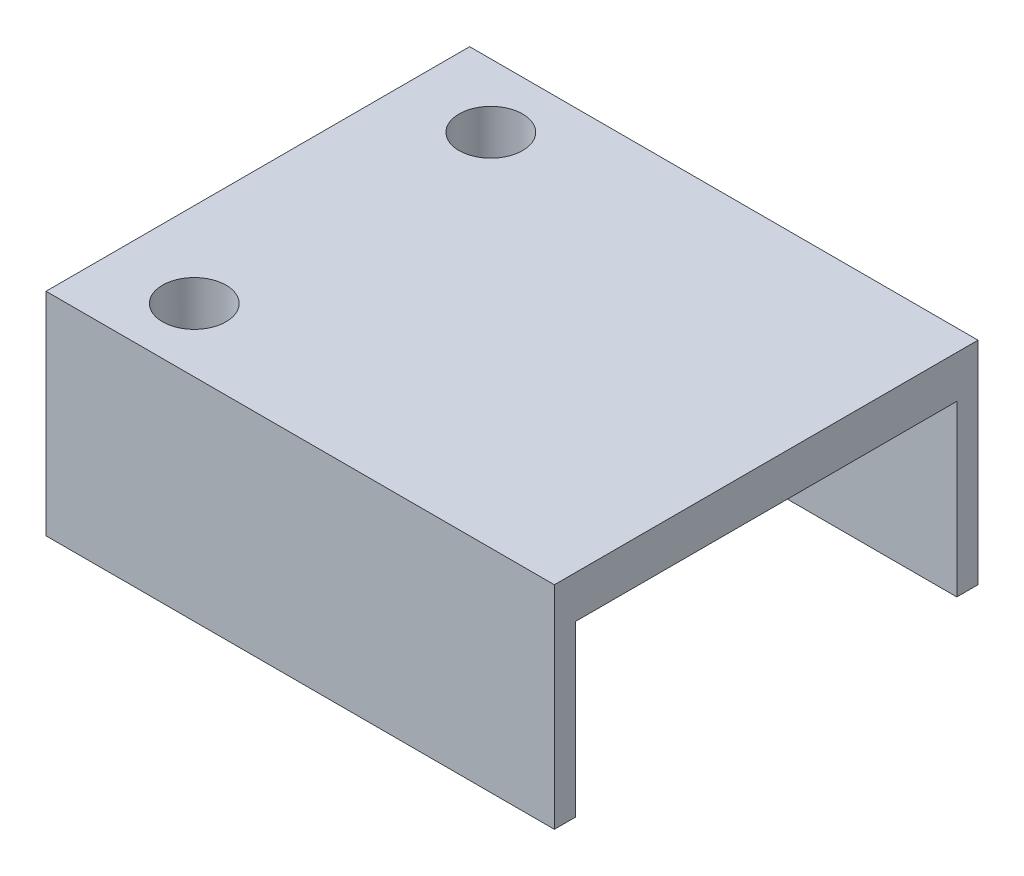
from build123d import *

# Parameters (mm, degrees)
ESQUISSE1_W             = 22
ESQUISSE1_H             = 10
BOSS_EXTRU_1_DEPTH      = 20
ESQUISSE2_R             = 1.5
ENL_V_MAT_EXTRU_1_DEPTH = 20
ESQUISSE4_W             = 18
ESQUISSE4_H             = 8
ENL_V_MAT_EXTRU_6_DEPTH = 18
ESQUISSE5_W             = 20
ESQUISSE5_H             = 10
BOSS_EXTRU_2_DEPTH      = 2
ESQUISSE6_W             = 8.5
ESQUISSE6_H             = 7.090406213
ENL_V_MAT_EXTRU_7_DEPTH = 8
CONG_1_R                = 5


with BuildPart() as part:
    # Esquisse1 → Boss.-Extru.1 (new body)
    with BuildSketch(Plane.XY):
        with Locations((11, 5)):
            Rectangle(ESQUISSE1_W, ESQUISSE1_H)
    extrude(amount=BOSS_EXTRU_1_DEPTH)

    # Esquisse2 → Enlèv. mat.-Extru.1 (cut)
    with BuildSketch(Plane(origin=(0, 10, 0), x_dir=(1, 0, 0), z_dir=(0, 1, 0))):
        with Locations((2, -3)):
            Circle(ESQUISSE2_R)
        with Locations((2, -17)):
            Circle(ESQUISSE2_R)
    extrude(amount=-ENL_V_MAT_EXTRU_1_DEPTH, mode=Mode.SUBTRACT)

    # Esquisse4 → Enlèv. mat.-Extru.6 (cut)
    with BuildSketch(Plane(origin=(22, 0, 0), x_dir=(0, 0, -1), z_dir=(1, 0, 0))):
        with Locations((-10, 4)):
            Rectangle(ESQUISSE4_W, ESQUISSE4_H)
    extrude(amount=-ENL_V_MAT_EXTRU_6_DEPTH, mode=Mode.SUBTRACT)

    # Esquisse5 → Boss.-Extru.2 (add)
    with BuildSketch(Plane.ZY):
        with Locations((10, 5)):
            Rectangle(ESQUISSE5_W, ESQUISSE5_H)
    extrude(amount=BOSS_EXTRU_2_DEPTH)

    # Esquisse6 → Enlèv. mat.-Extru.7 (cut)
    with BuildSketch(Plane.ZY.offset(2)):
        with Locations((10, 3.545203107)):
            Rectangle(ESQUISSE6_W, ESQUISSE6_H)
    extrude(amount=-ENL_V_MAT_EXTRU_7_DEPTH, mode=Mode.SUBTRACT)

    # Congé1
    cong_1_edges = [part.edges().sort_by_distance(p)[0] for p in [
        (4, 4, 1),
        (4, 4, 19),
    ]]
    fillet(cong_1_edges, radius=CONG_1_R)


solid = part.part
